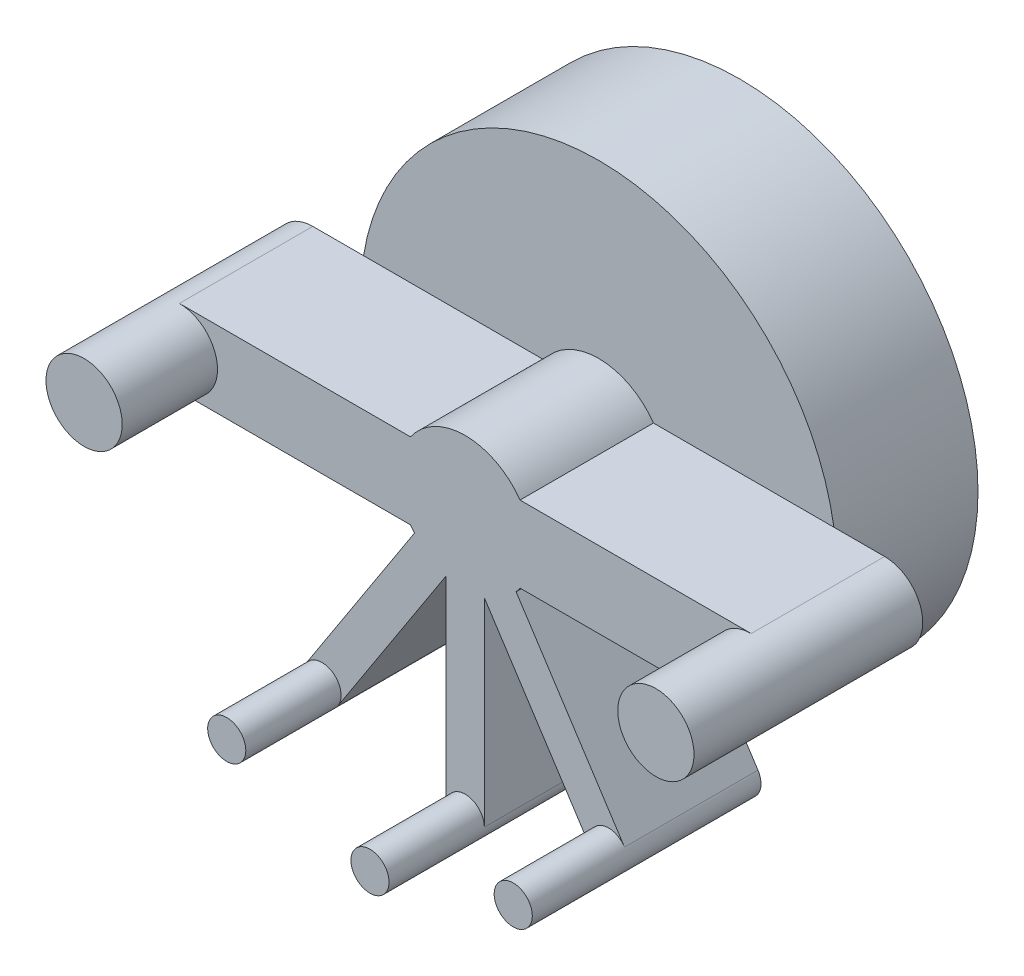
from build123d import *

# Parameters (mm, degrees)
SUPPORT_DEPTH              = 3.5
MAIN_FEATURES_SKETCH_3_R   = 6.25
KNOB_DEPTH                 = 3.7
SHAFT_START                = -3.7
MAIN_FEATURES_SKETCH_4_R   = 1.75
SHAFT_DEPTH                = 0.9
LEGS_START                 = 3.5
MAIN_FEATURES_SKETCH_5_R   = 1
MAIN_FEATURES_SKETCH_5_R_2 = 0.5
LEGS_DEPTH                 = 2.5


with BuildPart() as part:
    # main_features_sketch → support (new body)
    with BuildSketch(Plane.XY):
        with BuildLine():
            Line((0.5, -6.9), (0.5, -1.687971711))
            Line((0.5, -1.687971711), (3.338674058, -6.059146436))
            ThreePointArc((3.338674058, -6.059146436), (4.030328859, -6.206162203), (4.177344626, -5.514507401))
            Line((4.177344626, -5.514507401), (1.332722713, -1.134173783))
            ThreePointArc((1.332722713, -1.134173783), (1.386056185, -1.068339015), (1.436140662, -1))
            Line((1.436140662, -1), (7.5, -1))
            ThreePointArc((7.5, -1), (8.5, 0), (7.5, 1))
            Line((7.5, 1), (1.436140662, 1))
            ThreePointArc((1.436140662, 1), (0, 1.75), (-1.436140662, 1))
            Line((-1.436140662, 1), (-7.5, 1))
            ThreePointArc((-7.5, 1), (-8.5, 0), (-7.5, -1))
            Line((-7.5, -1), (-1.436140662, -1))
            ThreePointArc((-1.436140662, -1), (-1.386056185, -1.068339015), (-1.332722713, -1.134173783))
            Line((-1.332722713, -1.134173783), (-4.177344626, -5.514507401))
            ThreePointArc((-4.177344626, -5.514507401), (-4.030328859, -6.206162203), (-3.338674058, -6.059146436))
            Line((-3.338674058, -6.059146436), (-0.5, -1.687971711))
            Line((-0.5, -1.687971711), (-0.5, -6.9))
            ThreePointArc((-0.5, -6.9), (0, -7.4), (0.5, -6.9))
        make_face()
    extrude(amount=SUPPORT_DEPTH)

    # main_features_sketch_3 → knob (add)
    with BuildSketch(Plane.XY):
        Circle(MAIN_FEATURES_SKETCH_3_R)
    extrude(amount=-KNOB_DEPTH)

    # main_features_sketch_4 → shaft (add)
    with BuildSketch(Plane.XY.offset(SHAFT_START)):
        Circle(MAIN_FEATURES_SKETCH_4_R)
    extrude(amount=-SHAFT_DEPTH)

    # main_features_sketch_5 → legs (add)
    with BuildSketch(Plane.XY.offset(LEGS_START)):
        with Locations(Location((-7.5, 0, 0), (0, 0, 270))):
            Circle(MAIN_FEATURES_SKETCH_5_R)
        with Locations(Location((-3.758009342, -5.786826919, 0), (0, 0, 147))):
            Circle(MAIN_FEATURES_SKETCH_5_R_2)
        with Locations((0, -6.9)):
            Circle(MAIN_FEATURES_SKETCH_5_R_2)
        with Locations(Location((3.758009342, -5.786826919, 0), (0, 0, 213))):
            Circle(MAIN_FEATURES_SKETCH_5_R_2)
        with Locations(Location((7.5, 0, 0), (0, 0, 90))):
            Circle(MAIN_FEATURES_SKETCH_5_R)
    extrude(amount=LEGS_DEPTH)


solid = part.part
